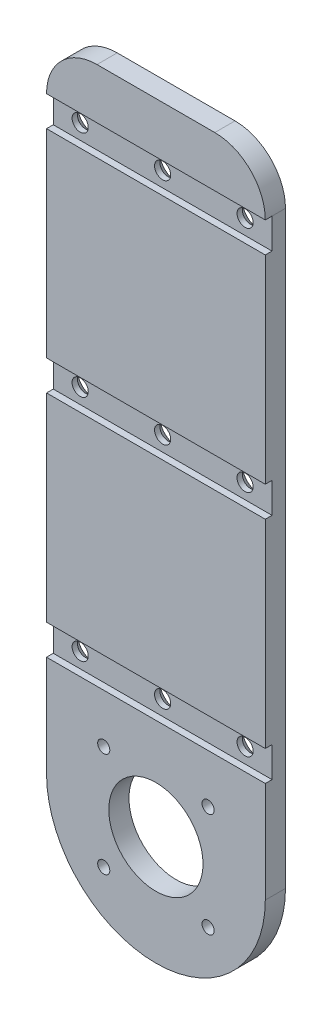
from build123d import *

# Parameters (mm, degrees)
BOSS_EXTRUDE1_DEPTH      = 6
M3_CLEARANCE_HOLE1_D     = 3.6
M3_CLEARANCE_HOLE1_DEPTH = 6
M3_CLEARANCE_HOLE1_TIP   = 1.081549114
FILLET1_R                = 15
SKETCH4_W                = 65
SKETCH4_H                = 9
SKETCH4_W_2              = 32.5
CUT_EXTRUDE1_DEPTH       = 2
M4_CLEARANCE_HOLE1_D     = 4.8
M4_CLEARANCE_HOLE1_DEPTH = 6
M4_CLEARANCE_HOLE1_TIP   = 1.442065486
CHAMFER1_SIZE            = 2.4


with BuildPart() as part:
    # Sketch1 → Boss-Extrude1 (new body)
    with BuildSketch(Plane.XY):
        with BuildLine():
            Line((-32.5, 95), (-32.5, -95))
            ThreePointArc((-32.5, -95), (0, -62.5), (32.5, -95))
            Line((32.5, -95), (32.5, 95))
            Line((32.5, 95), (-32.5, 95))
        make_face()
        with BuildLine():
            ThreePointArc((32.5, -95), (0, -62.5), (-32.5, -95))
            Line((-32.5, -95), (-15.5, -95))
            Line((-15.5, -95), (-15.5, -79.5))
            Line((-15.5, -79.5), (15.5, -79.5))
            Line((15.5, -79.5), (15.5, -95))
            Line((15.5, -95), (32.5, -95))
        make_face()
        with BuildLine():
            Line((-15.5, -95), (-32.5, -95))
            ThreePointArc((-32.5, -95), (0, -127.5), (32.5, -95))
            Line((32.5, -95), (15.5, -95))
            Line((15.5, -95), (15.5, -110.5))
            Line((15.5, -110.5), (-15.5, -110.5))
            Line((-15.5, -110.5), (-15.5, -95))
        make_face()
        with BuildLine():
            Line((-14, -95), (-15.5, -95))
            Line((-15.5, -95), (-15.5, -110.5))
            Line((-15.5, -110.5), (15.5, -110.5))
            Line((15.5, -110.5), (15.5, -95))
            Line((15.5, -95), (14, -95))
            ThreePointArc((14, -95), (0, -109), (-14, -95))
        make_face()
        with BuildLine():
            Line((-15.5, -79.5), (-15.5, -95))
            Line((-15.5, -95), (-14, -95))
            ThreePointArc((-14, -95), (0, -81), (14, -95))
            Line((14, -95), (15.5, -95))
            Line((15.5, -95), (15.5, -79.5))
            Line((15.5, -79.5), (-15.5, -79.5))
        make_face()
    extrude(amount=BOSS_EXTRUDE1_DEPTH)

    # M3 Clearance Hole1
    with Locations(Plane(origin=(0, 0, 0), x_dir=(-1, 0, 0), z_dir=(0, 0, -1))):
        with Locations((-15.5, -110.5), (15.5, -110.5), (15.5, -79.5), (-15.5, -79.5)):
            Hole(M3_CLEARANCE_HOLE1_D / 2, depth=M3_CLEARANCE_HOLE1_DEPTH)
            with Locations((0, 0, -(M3_CLEARANCE_HOLE1_DEPTH + M3_CLEARANCE_HOLE1_TIP / 2))):  # 118° drill point
                Cone(0, M3_CLEARANCE_HOLE1_D / 2, M3_CLEARANCE_HOLE1_TIP, mode=Mode.SUBTRACT)

    # Fillet1
    fillet1_edges = [part.edges().sort_by_distance(p)[0] for p in [
        (-32.5, 95, 3),
        (32.5, 95, 3),
    ]]
    fillet(fillet1_edges, radius=FILLET1_R)

    # Sketch4 → Cut-Extrude1 (cut)
    with BuildSketch(Plane.XY.offset(6)):
        with Locations((0, 75.5)):
            Rectangle(SKETCH4_W, SKETCH4_H)
        with Locations((-16.25, 7.5)):
            Rectangle(SKETCH4_W_2, SKETCH4_H)
        with Locations((16.25, 7.5)):
            Rectangle(SKETCH4_W_2, SKETCH4_H)
        with Locations((0, -60.5)):
            Rectangle(SKETCH4_W, SKETCH4_H)
    extrude(amount=-CUT_EXTRUDE1_DEPTH, mode=Mode.SUBTRACT)

    # M4 Clearance Hole1
    with Locations(Plane.XY.offset(4)):
        with Locations((-24.5, -60.5), (-24.5, 75.5), (24.5, 75.5), (0, 75.5), (-24.5, 7.5), (0, 7.5), (24.5, 7.5), (24.5, -60.5), (0, -60.5)):
            Hole(M4_CLEARANCE_HOLE1_D / 2, depth=M4_CLEARANCE_HOLE1_DEPTH)
            with Locations((0, 0, -(M4_CLEARANCE_HOLE1_DEPTH + M4_CLEARANCE_HOLE1_TIP / 2))):  # 118° drill point
                Cone(0, M4_CLEARANCE_HOLE1_D / 2, M4_CLEARANCE_HOLE1_TIP, mode=Mode.SUBTRACT)

    # Chamfer1
    chamfer1_edges = [part.edges().sort_by_distance(p)[0] for p in [
        (-22.1, -60.5, 0),
        (2.4, -60.5, 0),
        (26.9, -60.5, 0),
        (26.9, 7.5, 0),
        (2.4, 7.5, 0),
        (-22.1, 7.5, 0),
        (2.4, 75.5, 0),
        (26.9, 75.5, 0),
        (-22.1, 75.5, 0),
        (13.7, -79.5, 0),
        (-17.3, -79.5, 0),
        (-17.3, -110.5, 0),
        (13.7, -110.5, 0),
    ]]
    chamfer(chamfer1_edges, length=CHAMFER1_SIZE)


solid = part.part
